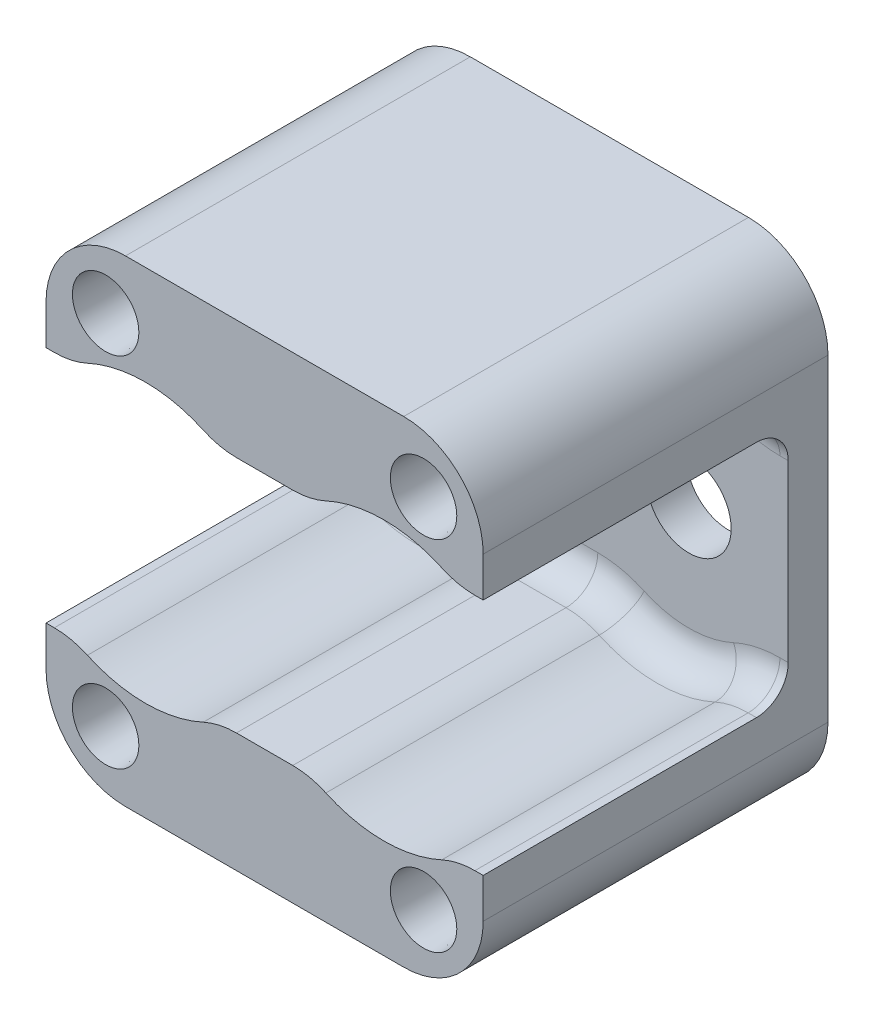
from build123d import *

# Parameters (mm, degrees)
SKETCH1_W               = 34.925
SKETCH1_H               = 38.1
BOSS_EXTRUDE1_DEPTH     = 3.175
SKETCH2_W               = 34.925
SKETCH2_H               = 9.525
BOSS_EXTRUDE2_DEPTH     = 24.3713
CUT_EXTRUDE1_START      = -16.4338
SKETCH3_R               = 11.1125
CUT_EXTRUDE1_DEPTH      = 25.3713
FILLET1_R               = 6.35
FILLET2_R               = 2.54
CUT_EXTRUDE2_DEPTH      = 4.175
F_1_4_CLEARANCE_HOLE1_D = 6.7564
F_6_CLEARANCE_HOLE1_D   = 4.3053
HOLE1_AT_2_COUNT        = 2
HOLE1_AT_2_PITCH        = 25.4
HOLE1_AT_3_COUNT        = 2
HOLE1_AT_3_PITCH        = 28.575
HOLE1_AT_4_COUNT        = 2
HOLE1_AT_4_PITCH        = 38.232062788


with BuildPart() as part:
    # Sketch1 → Boss-Extrude1 (new body)
    with BuildSketch(Plane.XY):
        with Locations((-9.525, 0)):
            Rectangle(SKETCH1_W, SKETCH1_H)
    extrude(amount=BOSS_EXTRUDE1_DEPTH)

    # Sketch2 → Boss-Extrude2 (add)
    with BuildSketch(Plane.XY.offset(3.175)):
        with Locations((-9.525, 14.2875)):
            Rectangle(SKETCH2_W, SKETCH2_H)
    boss_extrude2 = extrude(amount=BOSS_EXTRUDE2_DEPTH)

    # Sketch3 → Cut-Extrude1 (cut)
    with BuildSketch(Plane.XY.offset(19.6088).offset(CUT_EXTRUDE1_START)):
        Circle(SKETCH3_R)
        with Locations((-19.05, 0)):
            Circle(SKETCH3_R)
    cut_extrude1 = extrude(amount=CUT_EXTRUDE1_DEPTH, mode=Mode.SUBTRACT)

    # Mirror1: Boss-Extrude2, Cut-Extrude1 across plane
    add(boss_extrude2.mirror(Plane.ZX))
    add(cut_extrude1.mirror(Plane.ZX), mode=Mode.SUBTRACT)

    # Fillet1
    fillet1_edges = [part.edges().sort_by_distance(p)[0] for p in [
        (7.9375, 19.05, 13.77315),
        (-26.9875, 19.05, 13.77315),
        (5.72381265, 9.525, 15.36065),
        (-5.72381265, 9.525, 15.36065),
        (-13.32618735, 9.525, 15.36065),
        (-24.77381265, 9.525, 15.36065),
        (7.9375, -19.05, 13.77315),
        (-26.9875, -19.05, 13.77315),
        (5.72381265, -9.525, 15.36065),
        (-5.72381265, -9.525, 15.36065),
        (-13.32618735, -9.525, 15.36065),
        (-24.77381265, -9.525, 15.36065),
    ]]
    fillet(fillet1_edges, radius=FILLET1_R)

    # Fillet2
    fillet2_edges = [part.edges().sort_by_distance(p)[0] for p in [
        (7.606169458, 9.525, 3.175),
        (5.921014367, 9.670996527, 3.175),
        (0, 11.1125, 3.175),
        (-5.921014367, 9.670996527, 3.175),
        (-13.128985633, 9.670996527, 3.175),
        (-19.05, 11.1125, 3.175),
        (-24.971014367, 9.670996527, 3.175),
        (-26.656169458, 9.525, 3.175),
        (-9.525, 9.525, 3.175),
        (7.606169458, -9.525, 3.175),
        (5.921014367, -9.670996527, 3.175),
        (0, -11.1125, 3.175),
        (-5.921014367, -9.670996527, 3.175),
        (-9.525, -9.525, 3.175),
        (-13.128985633, -9.670996527, 3.175),
        (-19.05, -11.1125, 3.175),
        (-24.971014367, -9.670996527, 3.175),
        (-26.656169458, -9.525, 3.175),
    ]]
    fillet(fillet2_edges, radius=FILLET2_R)

    # Sketch4 → Cut-Extrude2 (cut, through all)
    with BuildSketch(Plane.XY.offset(3.175)):
        with BuildLine():
            Line((-19.899380011, 4.750666227), (-15.090170105, 2.758627051))
            ThreePointArc((-15.090170105, 2.758627051), (-15.28988845, -3.025200346), (-20.896829618, -4.458642883))
            ThreePointArc((-20.896829618, -4.458642883), (-23.8479402, 0.519659348), (-19.899380011, 4.750666227))
        make_face()
    extrude(amount=-CUT_EXTRUDE2_DEPTH, mode=Mode.SUBTRACT)

    # 1/4 Clearance Hole1 (through all)
    with Locations(Plane.XY.offset(3.175)):
        with Locations((0, 0)):
            Hole(F_1_4_CLEARANCE_HOLE1_D / 2)

    # #6 Clearance Hole1 (through all)
    with Locations(Plane(origin=(0, 0, 0), x_dir=(-1, 0, 0), z_dir=(0, 0, -1))):
        with Locations((-3.175, 14.2875), (22.225, 14.2875), (22.225, -14.2875), (-3.175, -14.2875)):
            Hole(F_6_CLEARANCE_HOLE1_D / 2)

    # Sketch9 → Hole1 (revolve, cut)
    with BuildSketch(Plane(origin=(-22.225, 14.2875, 27.5463), x_dir=(0, -1, 0), z_dir=(1, 0, 0))):
        Polygon((0, 0), (0, 3.81), (2.5273, 3.81), (2.6543, 0), align=None)
    hole1 = revolve(axis=Axis((-22.225, 14.2875, -82.4537), (0, 0, 1)), mode=Mode.SUBTRACT)

    # Hole1 at 2: Hole1 ×2
    with Locations(*[(i * HOLE1_AT_2_PITCH, 0, 0) for i in range(1, HOLE1_AT_2_COUNT)]):
        add(hole1, mode=Mode.SUBTRACT)

    # Hole1 at 3: Hole1 ×2
    with Locations(*[(0, -i * HOLE1_AT_3_PITCH, 0) for i in range(1, HOLE1_AT_3_COUNT)]):
        add(hole1, mode=Mode.SUBTRACT)

    # Hole1 at 4: Hole1 ×2
    with Locations(*[Vector(0.664363839, -0.747409319, 0) * (i * HOLE1_AT_4_PITCH) for i in range(1, HOLE1_AT_4_COUNT)]):
        add(hole1, mode=Mode.SUBTRACT)


solid = part.part
